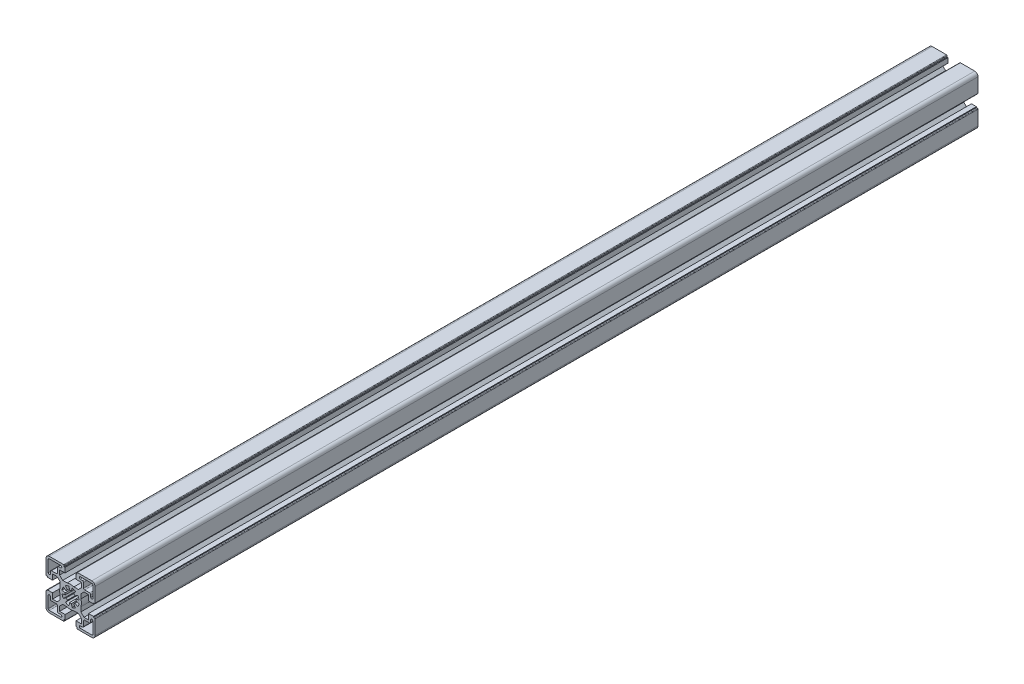
from build123d import *

# Parameters (mm, degrees)
BASE_EXTRUDE_DEPTH = 810


with BuildPart() as part:
    # Sketch1 → Base-Extrude (new body)
    with BuildSketch(Plane.XY):
        with BuildLine():
            Line((-4.99999574, -16.499883971), (-4.99999574, -20.99990968))
            Line((-4.99999574, -20.99990968), (-5.80004044, -20.99990968))
            Line((-5.80004044, -20.99990968), (-5.80004044, -21.999970054))
            ThreePointArc((-5.80004044, -21.999970054), (-5.946487232, -22.353523887), (-6.300041066, -22.49997068))
            Line((-6.300041066, -22.49997068), (-19.500014911, -22.49997068))
            ThreePointArc((-19.500014911, -22.49997068), (-21.62133367, -21.62129168), (-22.50001267, -19.499972921))
            Line((-22.50001267, -19.499972921), (-22.50001267, -6.299929564))
            ThreePointArc((-22.50001267, -6.299929564), (-22.353566213, -5.946376541), (-22.00001319, -5.799930084))
            Line((-22.00001319, -5.799930084), (-21.000012806, -5.799930084))
            Line((-21.000012806, -5.799930084), (-21.000012806, -4.999940084))
            Line((-21.000012806, -4.999940084), (-16.500012806, -4.999940084))
            Line((-16.500012806, -4.999940084), (-16.500012806, -10.049940084))
            Line((-16.500012806, -10.049940084), (-12.342923806, -10.049940084))
            Line((-12.342923806, -10.049940084), (-9.499953806, -7.206970084))
            Line((-9.499953806, -7.206970084), (-9.499953806, -3.122617084))
            ThreePointArc((-9.499953806, -3.122617084), (-10.000013376, 6.1916e-05), (-9.499953806, 3.122740916))
            Line((-9.499953806, 3.122740916), (-9.499953806, 7.206970084))
            Line((-9.499953806, 7.206970084), (-12.342923806, 10.049940084))
            Line((-12.342923806, 10.049940084), (-16.500012806, 10.049940084))
            Line((-16.500012806, 10.049940084), (-16.500012806, 4.999940084))
            Line((-16.500012806, 4.999940084), (-21.000012806, 4.999940084))
            Line((-21.000012806, 4.999940084), (-21.000012806, 5.799930084))
            Line((-21.000012806, 5.799930084), (-22.00001319, 5.799930084))
            ThreePointArc((-22.00001319, 5.799930084), (-22.353566213, 5.946376541), (-22.50001267, 6.299929564))
            Line((-22.50001267, 6.299929564), (-22.50001267, 19.499972921))
            ThreePointArc((-22.50001267, 19.499972921), (-21.62133367, 21.62129168), (-19.500014911, 22.49997068))
            Line((-19.500014911, 22.49997068), (-6.299954884, 22.49997068))
            ThreePointArc((-6.299954884, 22.49997068), (-5.946364566, 22.353508775), (-5.799902661, 21.999918456))
            Line((-5.799902661, 21.999918456), (-5.799902661, 20.999918083))
            Line((-5.799902661, 20.999918083), (-4.99999574, 20.999918083))
            Line((-4.99999574, 20.999918083), (-4.99999574, 16.499989166))
            Line((-4.99999574, 16.499989166), (-10.050086009, 16.499989166))
            Line((-10.050086009, 16.499989166), (-10.050086009, 12.342794971))
            Line((-10.050086009, 12.342794971), (-7.207151696, 9.499860659))
            Line((-7.207151696, 9.499860659), (-3.122798696, 9.499860659))
            ThreePointArc((-3.122798696, 9.499860659), (-0.000120196, 9.999920064), (3.122558304, 9.499860659))
            Line((3.122558304, 9.499860659), (7.206958901, 9.499860659))
            Line((7.206958901, 9.499860659), (10.049884116, 12.342787875))
            Line((10.049884116, 12.342787875), (10.049884116, 16.499989166))
            Line((10.049884116, 16.499989166), (4.99999574, 16.499989166))
            Line((4.99999574, 16.499989166), (4.99999574, 20.999963909))
            Line((4.99999574, 20.999963909), (5.799902661, 20.999963909))
            Line((5.799902661, 20.999963909), (5.799902661, 21.999918456))
            ThreePointArc((5.799902661, 21.999918456), (5.946364566, 22.353508775), (6.299954884, 22.49997068))
            Line((6.299954884, 22.49997068), (19.500081571, 22.49997068))
            ThreePointArc((19.500081571, 22.49997068), (21.62140033, 21.62129168), (22.50007933, 19.499972921))
            Line((22.50007933, 19.499972921), (22.50007933, 6.299877709))
            ThreePointArc((22.50007933, 6.299877709), (22.35363283, 5.946324583), (22.000079704, 5.799878083))
            Line((22.000079704, 5.799878083), (20.999995421, 5.799878083))
            Line((20.999995421, 5.799878083), (20.999995421, 4.999941084))
            Line((20.999995421, 4.999941084), (16.499983596, 4.999941084))
            Line((16.499983596, 4.999941084), (16.499983596, 10.049940084))
            Line((16.499983596, 10.049940084), (12.342894596, 10.049940084))
            Line((12.342894596, 10.049940084), (9.499922596, 7.206970084))
            Line((9.499922596, 7.206970084), (9.499922596, 3.122735916))
            ThreePointArc((9.499922596, 3.122735916), (9.999982165, 5.6916e-05), (9.499922596, -3.122622084))
            Line((9.499922596, -3.122622084), (9.499922596, -7.206970084))
            Line((9.499922596, -7.206970084), (12.342894596, -10.049940084))
            Line((12.342894596, -10.049940084), (16.499983596, -10.049940084))
            Line((16.499983596, -10.049940084), (16.499983596, -4.999941084))
            Line((16.499983596, -4.999941084), (20.999995421, -4.999941084))
            Line((20.999995421, -4.999941084), (20.999995421, -5.799878083))
            Line((20.999995421, -5.799878083), (22.000079704, -5.799878083))
            ThreePointArc((22.000079704, -5.799878083), (22.35363283, -5.946324583), (22.50007933, -6.299877709))
            Line((22.50007933, -6.299877709), (22.50007933, -19.499973421))
            ThreePointArc((22.50007933, -19.499973421), (21.621400476, -21.621291826), (19.500082071, -22.49997068))
            Line((19.500082071, -22.49997068), (6.300041066, -22.49997068))
            ThreePointArc((6.300041066, -22.49997068), (5.946487232, -22.353523887), (5.80004044, -21.999970054))
            Line((5.80004044, -21.999970054), (5.80004044, -20.99990968))
            Line((5.80004044, -20.99990968), (4.99999574, -20.99990968))
            Line((4.99999574, -20.99990968), (4.99999574, -16.499883971))
            Line((4.99999574, -16.499883971), (10.049884116, -16.499883971))
            Line((10.049884116, -16.499883971), (10.049884116, -12.342787875))
            Line((10.049884116, -12.342787875), (7.206933602, -9.49983536))
            Line((7.206933602, -9.49983536), (3.122579602, -9.49983536))
            ThreePointArc((3.122579602, -9.49983536), (-9.9398e-05, -9.99989493), (-3.122778398, -9.49983536))
            Line((-3.122778398, -9.49983536), (-7.207126398, -9.49983536))
            Line((-7.207126398, -9.49983536), (-10.050086009, -12.342794971))
            Line((-10.050086009, -12.342794971), (-10.050086009, -16.499883971))
            Line((-10.050086009, -16.499883971), (-4.99999574, -16.499883971))
        make_face()
        with BuildLine():
            Line((0.868239441, 4.924019626), (1.389186106, 7.878448412))
            ThreePointArc((1.389186106, 7.878448412), (3.061471579, 7.391020172), (4.588617704, 6.553195784))
            Line((4.588617704, 6.553195784), (2.867879873, 4.095738521))
            ThreePointArc((2.867879873, 4.095738521), (3.535523556, 3.535517244), (4.095743641, 2.867872561))
            Line((4.095743641, 2.867872561), (6.553203976, 4.588606005))
            ThreePointArc((6.553203976, 4.588606005), (7.391023332, 3.061463952), (7.878448799, 1.389183909))
            Line((7.878448799, 1.389183909), (4.924019868, 0.868238068))
            ThreePointArc((4.924019868, 0.868238068), (4.9999809, 7.81e-07), (4.924020139, -0.868236529))
            Line((4.924020139, -0.868236529), (7.878449234, -1.389181447))
            ThreePointArc((7.878449234, -1.389181447), (7.391025132, -3.061459606), (6.553207937, -4.588600349))
            Line((6.553207937, -4.588600349), (4.095746117, -2.867869026))
            ThreePointArc((4.095746117, -2.867869026), (3.535522832, -3.535517968), (2.86787466, -4.095742171))
            Line((2.86787466, -4.095742171), (4.588609364, -6.553201624))
            ThreePointArc((4.588609364, -6.553201624), (3.061466598, -7.391022236), (1.389185513, -7.878448517))
            Line((1.389185513, -7.878448517), (0.868239071, -4.924019691))
            ThreePointArc((0.868239071, -4.924019691), (8.15e-07, -4.9999809), (-0.868237465, -4.924019974))
            Line((-0.868237465, -4.924019974), (-1.389182943, -7.87844897))
            ThreePointArc((-1.389182943, -7.87844897), (-3.06146423, -7.391023216), (-4.588607303, -6.553203067))
            Line((-4.588607303, -6.553203067), (-2.867873372, -4.095743073))
            ThreePointArc((-2.867873372, -4.095743073), (-3.535520061, -3.535520739), (-4.095742523, -2.867874158))
            Line((-4.095742523, -2.867874158), (-6.553202186, -4.588608561))
            ThreePointArc((-6.553202186, -4.588608561), (-7.391024272, -3.061461681), (-7.878450195, -1.389175997))
            Line((-7.878450195, -1.389175997), (-4.92402074, -0.868233124))
            ThreePointArc((-4.92402074, -0.868233124), (-4.9999809, 1.729e-06), (-4.924020139, 0.868236529))
            Line((-4.924020139, 0.868236529), (-7.878449234, 1.389181447))
            ThreePointArc((-7.878449234, 1.389181447), (-7.391023494, 3.061463561), (-6.553203027, 4.588607361))
            Line((-6.553203027, 4.588607361), (-4.095743048, 2.867873408))
            ThreePointArc((-4.095743048, 2.867873408), (-3.535525782, 3.535515019), (-2.867885877, 4.095734317))
            Line((-2.867885877, 4.095734317), (-4.588627311, 6.553189058))
            ThreePointArc((-4.588627311, 6.553189058), (-3.061465289, 7.391022778), (-1.389161147, 7.878452813))
            Line((-1.389161147, 7.878452813), (-0.868223842, 4.924022376))
            ThreePointArc((-0.868223842, 4.924022376), (7.92e-06, 4.9999809), (0.868239441, 4.924019626))
        make_face(mode=Mode.SUBTRACT)
        with BuildLine():
            Line((-17.500118733, -12.000017917), (-13.000117238, -12.000017917))
            ThreePointArc((-13.000117238, -12.000017917), (-12.293010985, -12.292910917), (-12.000117985, -13.00001717))
            Line((-12.000117985, -13.00001717), (-12.000117985, -17.49992083))
            ThreePointArc((-12.000117985, -17.49992083), (-11.707224985, -18.207027083), (-11.000118733, -18.499920083))
            Line((-11.000118733, -18.499920083), (-9.000117985, -18.499920083))
            ThreePointArc((-9.000117985, -18.499920083), (-8.000069068, -19.499969), (-9.000117985, -20.500017917))
            Line((-9.000117985, -20.500017917), (-19.500118733, -20.500017917))
            ThreePointArc((-19.500118733, -20.500017917), (-20.207224985, -20.207124917), (-20.500117985, -19.500018664))
            Line((-20.500117985, -19.500018664), (-20.500117985, -8.999920083))
            ThreePointArc((-20.500117985, -8.999920083), (-19.500117985, -7.999920083), (-18.500117985, -8.999920083))
            Line((-18.500117985, -8.999920083), (-18.500117985, -11.000018664))
            ThreePointArc((-18.500117985, -11.000018664), (-18.207224985, -11.707124917), (-17.500118733, -12.000017917))
        make_face(mode=Mode.SUBTRACT)
        with BuildLine():
            Line((13.000003267, -12.000017917), (17.500004762, -12.000017917))
            ThreePointArc((17.500004762, -12.000017917), (18.207111015, -11.707124917), (18.500004015, -11.000018664))
            Line((18.500004015, -11.000018664), (18.500004015, -9.000115751))
            ThreePointArc((18.500004015, -9.000115751), (19.500004015, -8.000115751), (20.500004015, -9.000115751))
            Line((20.500004015, -9.000115751), (20.500004015, -19.500018664))
            ThreePointArc((20.500004015, -19.500018664), (20.207111015, -20.207124917), (19.500004762, -20.500017917))
            Line((19.500004762, -20.500017917), (9.000004015, -20.500017917))
            ThreePointArc((9.000004015, -20.500017917), (7.999955097, -19.499969), (9.000004015, -18.499920083))
            Line((9.000004015, -18.499920083), (11.000004762, -18.499920083))
            ThreePointArc((11.000004762, -18.499920083), (11.707111015, -18.207027083), (12.000004015, -17.49992083))
            Line((12.000004015, -17.49992083), (12.000004015, -13.00001717))
            ThreePointArc((12.000004015, -13.00001717), (12.292897015, -12.292910917), (13.000003267, -12.000017917))
        make_face(mode=Mode.SUBTRACT)
        with BuildLine():
            Line((-17.500118733, 12.000017917), (-13.000117238, 12.000017917))
            ThreePointArc((-13.000117238, 12.000017917), (-12.293010985, 12.292910917), (-12.000117985, 13.00001717))
            Line((-12.000117985, 13.00001717), (-12.000117985, 17.49992083))
            ThreePointArc((-12.000117985, 17.49992083), (-11.707224985, 18.207027083), (-11.000118733, 18.499920083))
            Line((-11.000118733, 18.499920083), (-9.000117985, 18.499920083))
            ThreePointArc((-9.000117985, 18.499920083), (-8.000069068, 19.499969), (-9.000117985, 20.500017917))
            Line((-9.000117985, 20.500017917), (-19.500118733, 20.500017917))
            ThreePointArc((-19.500118733, 20.500017917), (-20.207224985, 20.207124917), (-20.500117985, 19.500018664))
            Line((-20.500117985, 19.500018664), (-20.500117985, 8.999920083))
            ThreePointArc((-20.500117985, 8.999920083), (-19.500117985, 7.999920083), (-18.500117985, 8.999920083))
            Line((-18.500117985, 8.999920083), (-18.500117985, 11.000018664))
            ThreePointArc((-18.500117985, 11.000018664), (-18.207224985, 11.707124917), (-17.500118733, 12.000017917))
        make_face(mode=Mode.SUBTRACT)
        with BuildLine():
            Line((13.000003267, 12.000017917), (17.500004762, 12.000017917))
            ThreePointArc((17.500004762, 12.000017917), (18.207111015, 11.707124917), (18.500004015, 11.000018664))
            Line((18.500004015, 11.000018664), (18.500004015, 9.000115751))
            ThreePointArc((18.500004015, 9.000115751), (19.500004015, 8.000115751), (20.500004015, 9.000115751))
            Line((20.500004015, 9.000115751), (20.500004015, 19.500018664))
            ThreePointArc((20.500004015, 19.500018664), (20.207111015, 20.207124917), (19.500004762, 20.500017917))
            Line((19.500004762, 20.500017917), (9.000004015, 20.500017917))
            ThreePointArc((9.000004015, 20.500017917), (7.999955097, 19.499969), (9.000004015, 18.499920083))
            Line((9.000004015, 18.499920083), (11.000004762, 18.499920083))
            ThreePointArc((11.000004762, 18.499920083), (11.707111015, 18.207027083), (12.000004015, 17.49992083))
            Line((12.000004015, 17.49992083), (12.000004015, 13.00001717))
            ThreePointArc((12.000004015, 13.00001717), (12.292897015, 12.292910917), (13.000003267, 12.000017917))
        make_face(mode=Mode.SUBTRACT)
    extrude(amount=BASE_EXTRUDE_DEPTH)


solid = part.part
